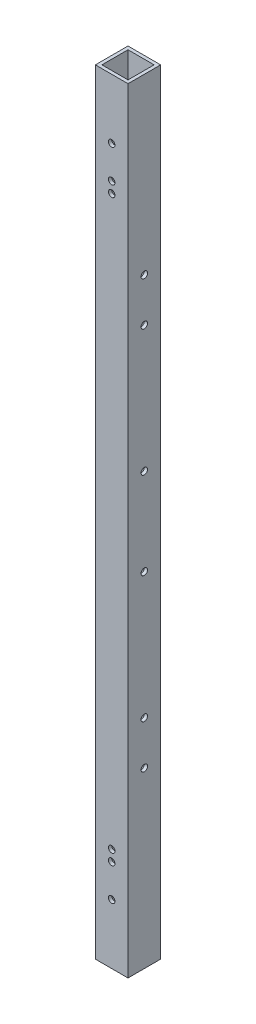
from build123d import *

# Parameters (mm, degrees)
SKETCH1_W           = 15
SKETCH1_H           = 15
SKETCH1_W_2         = 12
SKETCH1_H_2         = 12
EXTRUDE_THIN1_DEPTH = 356
SKETCH2_R           = 1.5
CUT_EXTRUDE1_DEPTH  = 357.631462437
SKETCH3_R           = 1.5
CUT_EXTRUDE2_DEPTH  = 357.631462437


with BuildPart() as part:
    # Sketch1 → Extrude-Thin1 (new body)
    with BuildSketch(Plane(origin=(0, 0, 0), x_dir=(1, 0, 0), z_dir=(0, 1, 0))):
        with Locations((7.5, 7.5)):
            Rectangle(SKETCH1_W, SKETCH1_H)
        with Locations((7.5, 7.5)):
            Rectangle(SKETCH1_W_2, SKETCH1_H_2, mode=Mode.SUBTRACT)
    extrude(amount=EXTRUDE_THIN1_DEPTH)

    # Sketch2 (on Front Plane) → Cut-Extrude1 (cut, through all)
    with BuildSketch(Plane.XY):
        with Locations((7.5, 27.5)):
            Circle(SKETCH2_R)
        with Locations((7.5, 47.5)):
            Circle(SKETCH2_R)
        with Locations((7.5, 42.5)):
            Circle(SKETCH2_R)
        with Locations((7.5, 328.5)):
            Circle(SKETCH2_R)
        with Locations((7.5, 313.5)):
            Circle(SKETCH2_R)
        with Locations((7.5, 308.5)):
            Circle(SKETCH2_R)
    extrude(amount=-CUT_EXTRUDE1_DEPTH, mode=Mode.SUBTRACT)

    # Sketch3 → Cut-Extrude2 (cut, through all)
    with BuildSketch(Plane(origin=(15, 0, 0), x_dir=(0, 0, -1), z_dir=(1, 0, 0))):
        with Locations((7.5, 276.148)):
            Circle(SKETCH3_R)
        with Locations((7.5, 256.148)):
            Circle(SKETCH3_R)
        with Locations((7.5, 198)):
            Circle(SKETCH3_R)
        with Locations((7.5, 158)):
            Circle(SKETCH3_R)
        with Locations((7.5, 99.852)):
            Circle(SKETCH3_R)
        with Locations((7.5, 79.852)):
            Circle(SKETCH3_R)
    extrude(amount=-CUT_EXTRUDE2_DEPTH, mode=Mode.SUBTRACT)


solid = part.part
